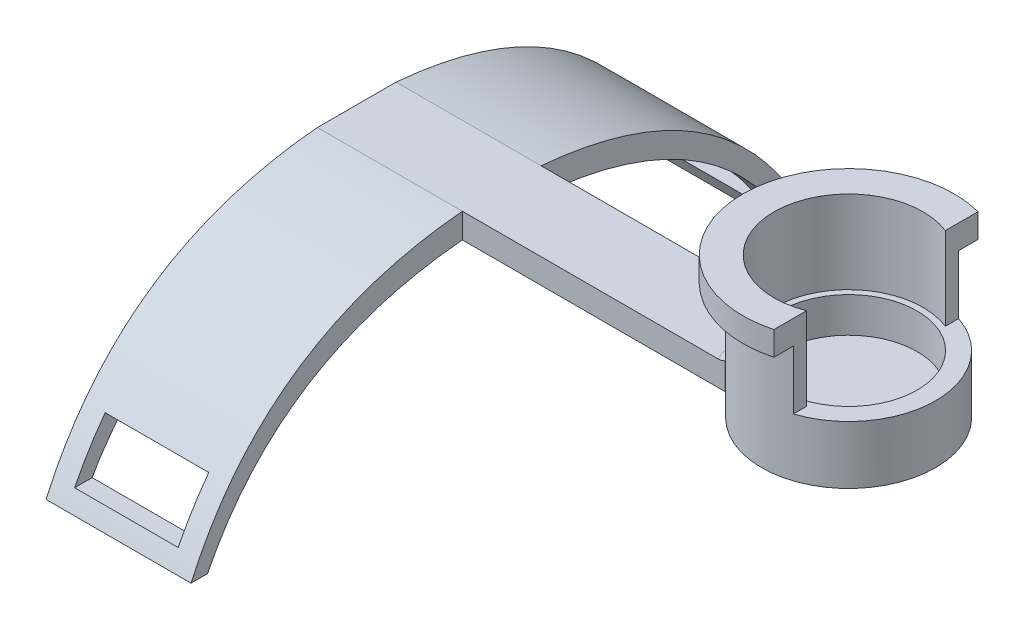
from build123d import *

# Parameters (mm, degrees)
F_0_1MM_FIT_FOR_POT_R   = 10.5
BOSS_EXTRUDE1_DEPTH     = 2.75
SKETCH4_R               = 10.5
SKETCH4_R_2             = 8.275
BOSS_EXTRUDE2_DEPTH     = 4.25
BOSS_EXTRUDE3_DEPTH     = 2
FILLET1_R               = 0.25
BOSS_EXTRUDE6_DEPTH     = 10
BOSS_EXTRUDE7_DEPTH     = 2.9
BOSS_EXTRUDE8_DEPTH     = 3
FILLET2_R               = 1.5
BOSS_EXTRUDE9_DEPTH     = 17.5
SKETCH11_W              = 12.5
SKETCH11_H              = 6
CUT_EXTRUDE1_DEPTH      = 76.428217957
CUT_EXTRUDE1_DEPTH_BACK = 76.428217957


with BuildPart() as part:
    # 0.1mm fit for pot → Boss-Extrude1 (new body)
    with BuildSketch(Plane(origin=(0, 0, 0), x_dir=(1, 0, 0), z_dir=(0, 1, 0))):
        with Locations(Location((0, 0, 0), (0, 0, 270))):
            Circle(F_0_1MM_FIT_FOR_POT_R)
    extrude(amount=BOSS_EXTRUDE1_DEPTH)

    # Sketch4 → Boss-Extrude2 (add)
    with BuildSketch(Plane(origin=(0, 2.75, 0), x_dir=(1, 0, 0), z_dir=(0, 1, 0))):
        with Locations(Location((0, 0, 0), (0, 0, 270))):
            Circle(SKETCH4_R)
        with Locations(Location((0, 0, 0), (0, 0, 270))):
            Circle(SKETCH4_R_2, mode=Mode.SUBTRACT)
    extrude(amount=BOSS_EXTRUDE2_DEPTH)

    # Sketch5 → Boss-Extrude3 (add)
    with BuildSketch(Plane(origin=(0, 2.75, 0), x_dir=(1, 0, 0), z_dir=(0, 1, 0))):
        with BuildLine():
            Line((-1, -8.214354813), (-1, -7.065799598))
            Line((-1, -7.065799598), (0.988059701, -7.065799598))
            Line((0.988059701, -7.065799598), (0.988059701, -8.215799598))
            ThreePointArc((0.988059701, -8.215799598), (-0.006013695, -8.274997815), (-1, -8.214354813))
        make_face()
    extrude(amount=BOSS_EXTRUDE3_DEPTH)

    # Fillet1
    fillet1_edges = [part.edges().sort_by_distance(p)[0] for p in [
        (0.988059701, 3.75, 7.065799598),
        (-1, 3.75, 7.065799598),
        (-0.005970149, 4.75, 7.065799598),
        (-1, 4.75, 7.640077205),
        (0.988059701, 4.75, 7.640799598),
    ]]
    fillet(fillet1_edges, radius=FILLET1_R)

    # Sketch7 → Boss-Extrude6 (add)
    with BuildSketch(Plane(origin=(0, 7, 0), x_dir=(1, 0, 0), z_dir=(0, 1, 0))):
        with BuildLine():
            Line((3.299602194, 9.968080325), (3.299602194, 8.373328213))
            ThreePointArc((3.299602194, 8.373328213), (-9, 0), (3.299602194, -8.373328213))
            Line((3.299602194, -8.373328213), (3.299602194, -9.968080325))
            ThreePointArc((3.299602194, -9.968080325), (-10.5, 0), (3.299602194, 9.968080325))
        make_face()
    extrude(amount=BOSS_EXTRUDE6_DEPTH)

    # Sketch8 → Boss-Extrude7 (add)
    with BuildSketch(Plane(origin=(0, 17, 0), x_dir=(1, 0, 0), z_dir=(0, 1, 0))):
        with BuildLine():
            Line((3.299602194, 12.315645552), (3.299602194, 9.968080325))
            ThreePointArc((3.299602194, 9.968080325), (-10.5, 0), (3.299602194, -9.968080325))
            Line((3.299602194, -9.968080325), (3.299602194, -12.315645552))
            ThreePointArc((3.299602194, -12.315645552), (-12.75, 0), (3.299602194, 12.315645552))
        make_face()
    extrude(amount=-BOSS_EXTRUDE7_DEPTH)

    # Sketch9 → Boss-Extrude8 (add)
    with BuildSketch(Plane.XZ):
        with BuildLine():
            Line((-9.3641604, 4.75), (-59.3641604, 4.75))
            Line((-59.3641604, 4.75), (-59.3641604, -4.75))
            Line((-59.3641604, -4.75), (-9.3641604, -4.75))
            ThreePointArc((-9.3641604, -4.75), (-10.5, 0), (-9.3641604, 4.75))
        make_face()
    extrude(amount=-BOSS_EXTRUDE8_DEPTH)

    # Fillet2
    fillet2_edges = [part.edges().sort_by_distance(p)[0] for p in [
        (-10.5, 3, 0),
        (-9.3641604, 1.5, 4.75),
        (-9.3641604, 1.5, -4.75),
    ]]
    fillet(fillet2_edges, radius=FILLET2_R)

    # Sketch10 → Boss-Extrude9 (add)
    with BuildSketch(Plane.ZY.offset(59.3641604)):
        with BuildLine():
            Line((-37.5, -19.5), (-35.5, -19.5))
            add(Edge.make_bspline(
                [(-4.75, 0), (-26.762186457, -1.948698647), (-35.5, -19.5)],
                knots=[0.548592822, 0.548592822, 0.548592822, 1, 1, 1], degree=2))
            Line((-4.75, 0), (4.75, 0))
            add(Edge.make_bspline(
                [(35.5, -19.5), (26.762186461, -1.948698647), (4.75, 0)],
                knots=[0, 0, 0, 0.451407178, 0.451407178, 0.451407178], degree=2))
            Line((35.5, -19.5), (37.5, -19.5))
            add(Edge.make_bspline(
                [(4.75, 3), (28.386779804, 0.912348176), (37.5, -19.5)],
                knots=[0.545557352, 0.545557352, 0.545557352, 1, 1, 1], degree=2))
            Line((4.75, 3), (-4.75, 3))
            add(Edge.make_bspline(
                [(-37.5, -19.5), (-28.386779803, 0.912348176), (-4.75, 3)],
                knots=[0, 0, 0, 0.454442648, 0.454442648, 0.454442648], degree=2))
        make_face()
    extrude(amount=-BOSS_EXTRUDE9_DEPTH)

    # Sketch11 → Cut-Extrude1 (cut, two sides)
    with BuildSketch(Plane(origin=(0, 0, -4.75), x_dir=(-1, 0, 0), z_dir=(0, 0, -1))) as cut_extrude1_sk:
        with Locations((50.6141604, -14.5)):
            Rectangle(SKETCH11_W, SKETCH11_H)
    extrude(amount=CUT_EXTRUDE1_DEPTH, mode=Mode.SUBTRACT)
    extrude(cut_extrude1_sk.sketch, amount=-CUT_EXTRUDE1_DEPTH_BACK, mode=Mode.SUBTRACT)


solid = part.part
